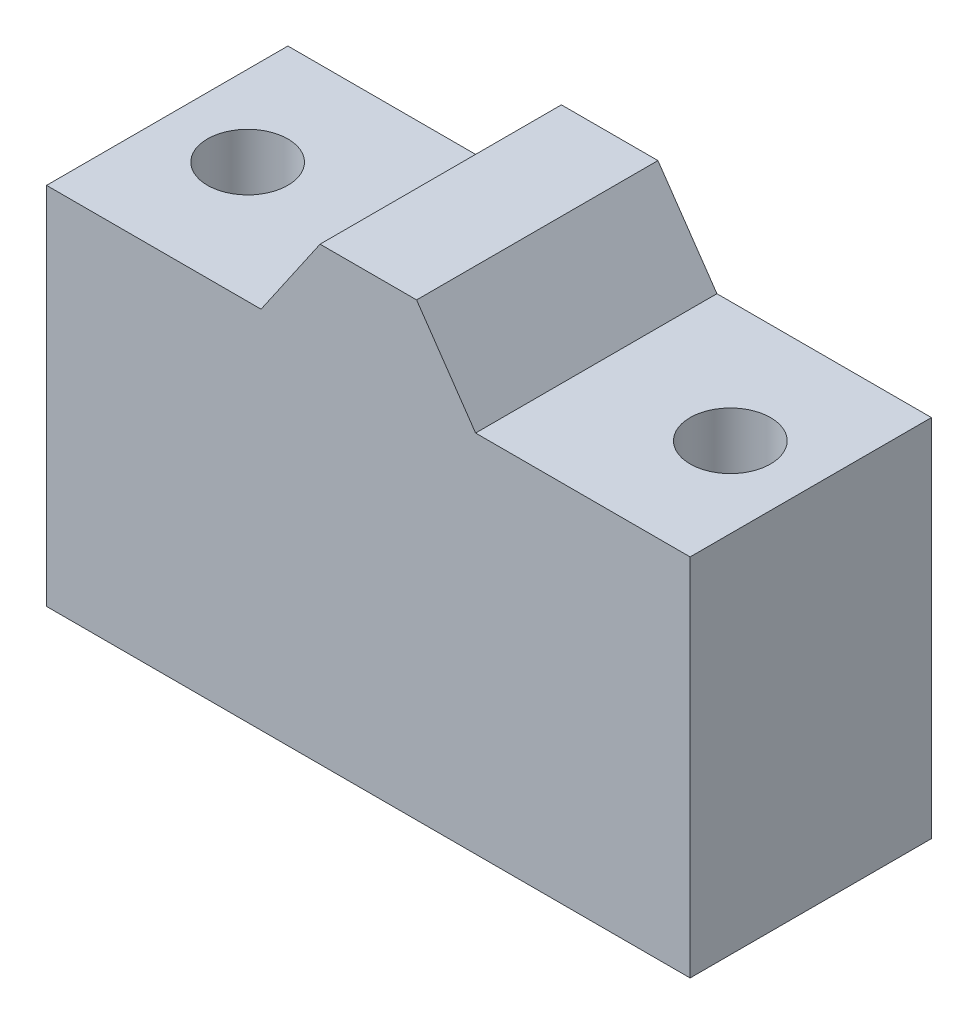
from build123d import *

# Parameters (mm, degrees)
BOSS_EXTRU_1_DEPTH      = 45
ESQUISSE2_R             = 7.5
BOSS_EXTRU_2_DEPTH      = 68
ESQUISSE2_4_R           = 7.5
ENL_V_MAT_EXTRU_1_DEPTH = 69


with BuildPart() as part:
    # Esquisse1 → Boss.-Extru.1 (new body)
    with BuildSketch(Plane.XY):
        Polygon((0, 0), (120, 0), (120, 68), (80, 68), (69, 84), (51, 84), (40, 68), (0, 68), align=None)
    extrude(amount=BOSS_EXTRU_1_DEPTH)

    # Esquisse2 → Boss.-Extru.2 (add, through all)
    with BuildSketch(Plane(origin=(0, 68, 0), x_dir=(1, 0, 0), z_dir=(0, 1, 0))):
        with Locations((105, -22.5)):
            Circle(ESQUISSE2_R)
        with Locations((15, -22.5)):
            Circle(ESQUISSE2_R)
    extrude(amount=-BOSS_EXTRU_2_DEPTH)

    # Esquisse2_4 → Enl_v. mat.-Extru.1 (cut, through all)
    with BuildSketch(Plane(origin=(0, 68, 0), x_dir=(1, 0, 0), z_dir=(0, 1, 0))):
        with Locations(Location((105, -22.5, 0), (0, 0, 180))):  # turned: the seam where the file's is
            Circle(ESQUISSE2_4_R)
        with Locations(Location((15, -22.5, 0), (0, 0, 180))):  # turned: the seam where the file's is
            Circle(ESQUISSE2_4_R)
    extrude(amount=-ENL_V_MAT_EXTRU_1_DEPTH, mode=Mode.SUBTRACT)


solid = part.part
